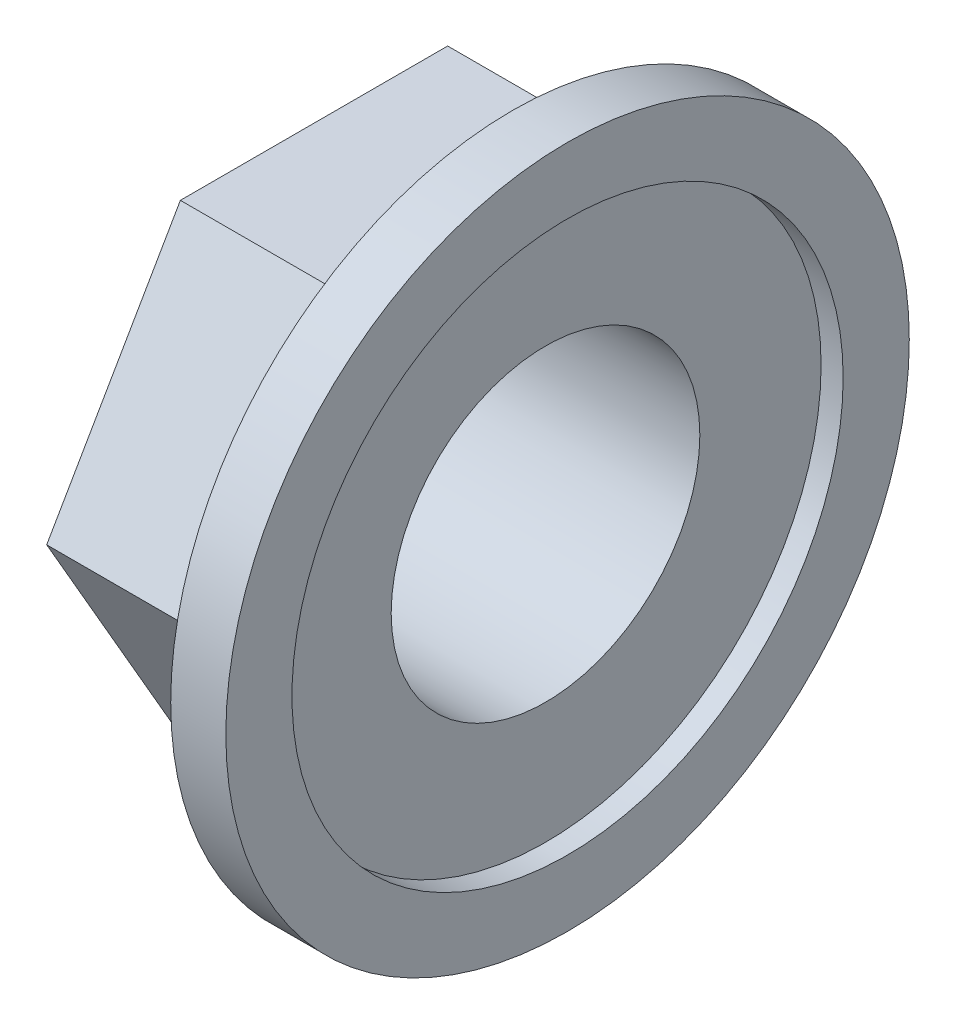
from build123d import *

# Parameters (mm, degrees)
SKETCH1_R               = 15.5
BOSS_EXTRUDE2_DEPTH     = 2.5
SKETCH2_R               = 12.5
CUT_EXTRUDE1_DEPTH      = 1
BOSS_EXTRUDE3_DEPTH     = 9
SKETCH4_R               = 7
CUT_EXTRUDE2_DEPTH      = 1
CUT_EXTRUDE2_DEPTH_BACK = 12.5


with BuildPart() as part:
    # Sketch1 → Boss-Extrude2 (new body)
    with BuildSketch(Plane(origin=(0, 0, 0), x_dir=(0, 0, -1), z_dir=(1, 0, 0))):
        Circle(SKETCH1_R)
    extrude(amount=BOSS_EXTRUDE2_DEPTH)

    # Sketch2 → Cut-Extrude1 (cut)
    with BuildSketch(Plane(origin=(2.5, 0, 0), x_dir=(0, 0, -1), z_dir=(1, 0, 0))):
        Circle(SKETCH2_R)
    extrude(amount=-CUT_EXTRUDE1_DEPTH, mode=Mode.SUBTRACT)

    # Sketch3 → Boss-Extrude3 (add)
    with BuildSketch(Plane.ZY):
        Polygon((12.124355653, 0), (6.062177826, 10.5), (-6.062177826, 10.5), (-12.124355653, 0), (-6.062177826, -10.5), (6.062177826, -10.5), align=None)
    extrude(amount=BOSS_EXTRUDE3_DEPTH)

    # Sketch4 → Cut-Extrude2 (cut, two sides)
    with BuildSketch(Plane.ZY.offset(9)) as cut_extrude2_sk:
        Circle(SKETCH4_R)
    extrude(amount=CUT_EXTRUDE2_DEPTH, mode=Mode.SUBTRACT)
    extrude(cut_extrude2_sk.sketch, amount=-CUT_EXTRUDE2_DEPTH_BACK, mode=Mode.SUBTRACT)


solid = part.part
